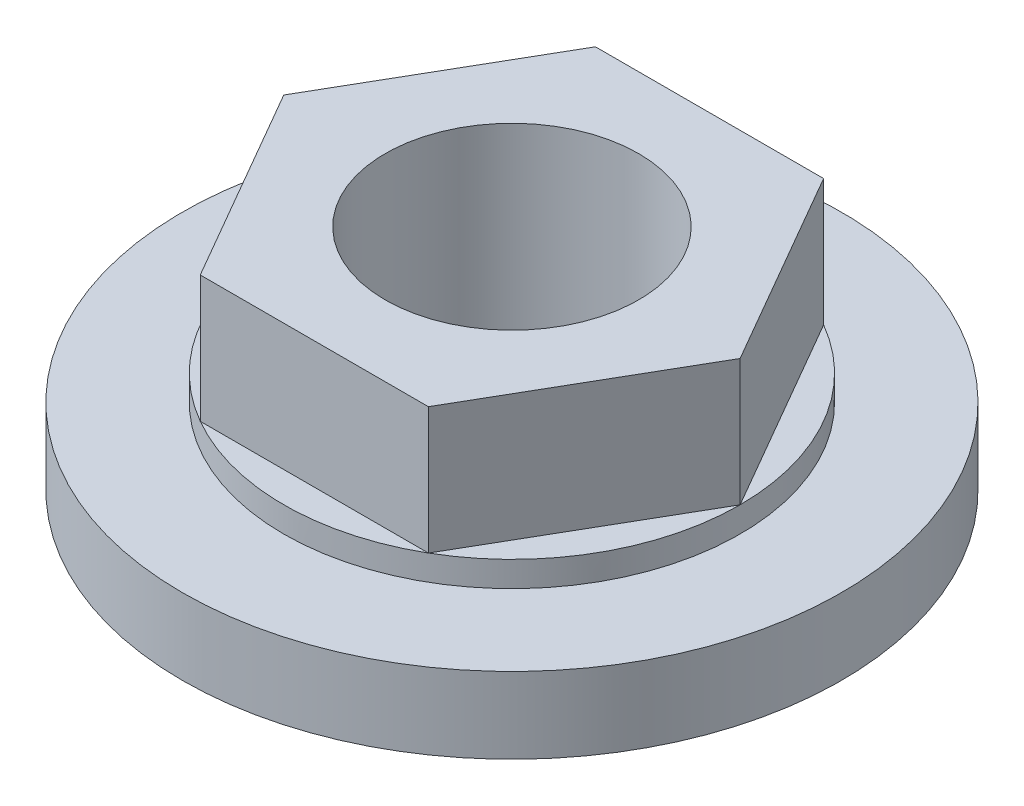
from build123d import *

# Parameters (mm, degrees)
SKETCH1_R           = 6.5
BOSS_EXTRUDE1_DEPTH = 1.5
SKETCH2_R           = 4.5
BOSS_EXTRUDE2_DEPTH = 0.5
SKETCH3_R           = 2.5
BOSS_EXTRUDE3_DEPTH = 2.5
SKETCH4_R           = 2.5
CUT_EXTRUDE1_DEPTH  = 3.5


with BuildPart() as part:
    # Sketch1 → Boss-Extrude1 (new body)
    with BuildSketch(Plane(origin=(0, 0, 0), x_dir=(1, 0, 0), z_dir=(0, 1, 0))):
        with Locations(Location((0, 0, 0), (0, 0, 270))):  # turned: the seam where the file's is
            Circle(SKETCH1_R)
    extrude(amount=BOSS_EXTRUDE1_DEPTH)

    # Sketch2 → Boss-Extrude2 (add)
    with BuildSketch(Plane(origin=(0, 1.5, 0), x_dir=(1, 0, 0), z_dir=(0, 1, 0))):
        with Locations(Location((0, 0, 0), (0, 0, 270))):  # turned: the seam where the file's is
            Circle(SKETCH2_R)
    extrude(amount=BOSS_EXTRUDE2_DEPTH)

    # Sketch3 → Boss-Extrude3 (add)
    with BuildSketch(Plane(origin=(0, 2, 0), x_dir=(1, 0, 0), z_dir=(0, 1, 0))):
        Polygon((-4.5, 0), (-2.25, -3.897114317), (2.25, -3.897114317), (4.5, 0), (2.25, 3.897114317), (-2.25, 3.897114317), align=None)
        with Locations(Location((0, 0, 0), (0, 0, 270))):  # turned: the seam where the file's is
            Circle(SKETCH3_R, mode=Mode.SUBTRACT)
    extrude(amount=BOSS_EXTRUDE3_DEPTH)

    # Sketch4 → Cut-Extrude1 (cut)
    with BuildSketch(Plane(origin=(0, 2, 0), x_dir=(1, 0, 0), z_dir=(0, 1, 0))):
        with Locations(Location((0, 0, 0), (0, 0, 270))):  # turned: the seam where the file's is
            Circle(SKETCH4_R)
    extrude(amount=-CUT_EXTRUDE1_DEPTH, mode=Mode.SUBTRACT)


solid = part.part
